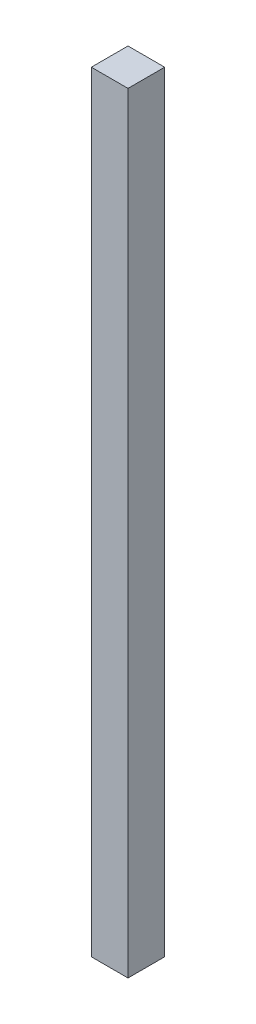
from build123d import *

# Parameters (mm, degrees)
SKETCH1_W           = 15
SKETCH1_H           = 15
BOSS_EXTRUDE1_DEPTH = 315


with BuildPart() as part:
    # Sketch1 → Boss-Extrude1 (new body)
    with BuildSketch(Plane(origin=(0, 0, 0), x_dir=(1, 0, 0), z_dir=(0, 1, 0))):
        Rectangle(SKETCH1_W, SKETCH1_H)
    extrude(amount=BOSS_EXTRUDE1_DEPTH)


solid = part.part
